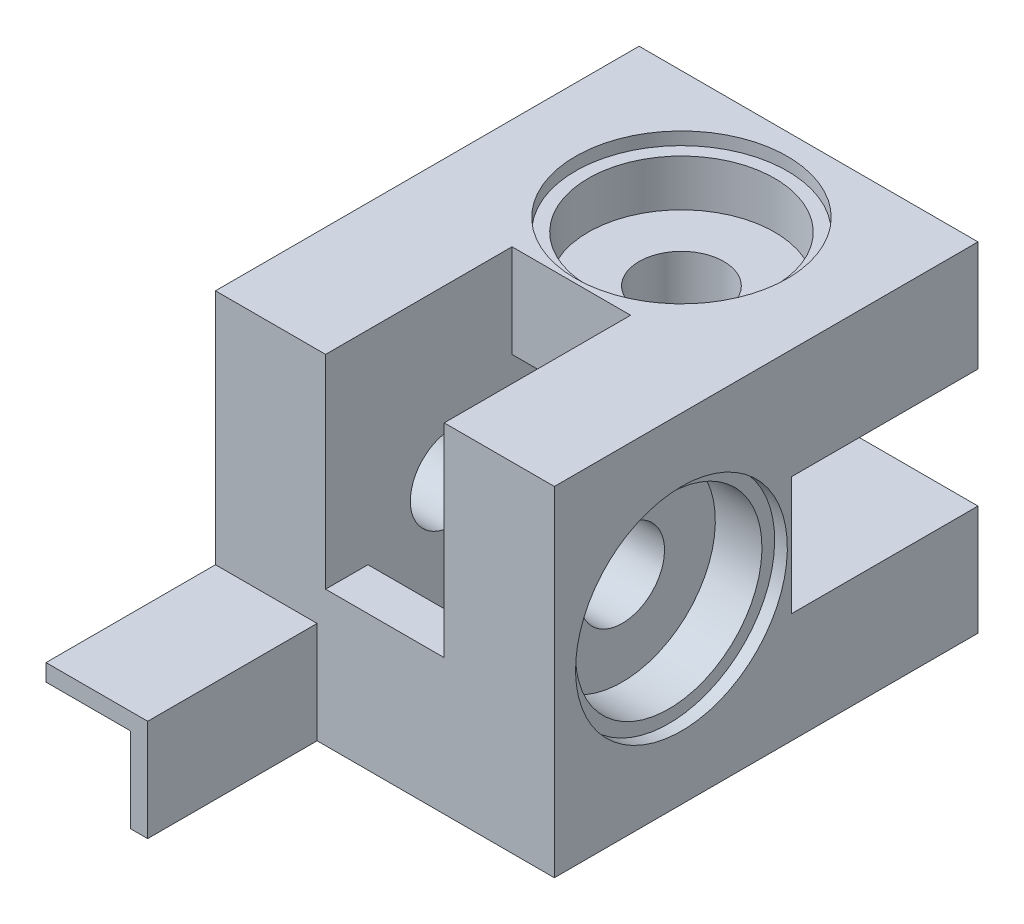
from build123d import *

# Parameters (mm, degrees)
ESQUISSE1_W              = 40
ESQUISSE1_H              = 40
BOSS_EXTRU_1_DEPTH       = 50
ESQUISSE2_R              = 5
ENL_V_MAT_EXTRU_1_DEPTH  = 41
ESQUISSE3_R              = 5
ENL_V_MAT_EXTRU_2_DEPTH  = 41
ESQUISSE4_W              = 20
ESQUISSE4_H              = 14
ENL_V_MAT_EXTRU_3_DEPTH  = 29
ESQUISSE5_W              = 14
ESQUISSE5_H              = 20
ENL_V_MAT_EXTRU_4_DEPTH  = 29
ESQUISSE6_W              = 22
ESQUISSE6_H              = 14
ENL_V_MAT_EXTRU_5_DEPTH  = 24
ESQUISSE7_W              = 14
ESQUISSE7_H              = 22
ENL_V_MAT_EXTRU_6_DEPTH  = 24
ESQUISSE8_R              = 11
ENL_V_MAT_EXTRU_7_DEPTH  = 7
ESQUISSE9_R              = 12.5
ENL_V_MAT_EXTRU_8_DEPTH  = 1.5
ESQUISSE10_R             = 11
ENL_V_MAT_EXTRU_9_DEPTH  = 7
ESQUISSE11_R             = 12.5
ENL_V_MAT_EXTRU_10_DEPTH = 1.5
BOSS_EXTRU_2_DEPTH       = 20


with BuildPart() as part:
    # Esquisse1 → Boss.-Extru.1 (new body)
    with BuildSketch(Plane.XY):
        with Locations((-20, 20)):
            Rectangle(ESQUISSE1_W, ESQUISSE1_H)
    extrude(amount=BOSS_EXTRU_1_DEPTH)

    # Esquisse2 → Enlèv. mat.-Extru.1 (cut, through all)
    with BuildSketch(Plane(origin=(0, 40, 0), x_dir=(1, 0, 0), z_dir=(0, 1, 0))):
        with Locations(Location((-20, -15, 0), (0, 0, 270))):  # turned: the seam where the file's is
            Circle(ESQUISSE2_R)
    extrude(amount=-ENL_V_MAT_EXTRU_1_DEPTH, mode=Mode.SUBTRACT)

    # Esquisse3 → Enlèv. mat.-Extru.2 (cut, through all)
    with BuildSketch(Plane.ZY.offset(40)):
        with Locations((35, 20)):
            Circle(ESQUISSE3_R)
    extrude(amount=-ENL_V_MAT_EXTRU_2_DEPTH, mode=Mode.SUBTRACT)

    # Esquisse4 → Enlèv. mat.-Extru.3 (cut)
    with BuildSketch(Plane.ZY.offset(40)):
        with Locations((15, 20)):
            Rectangle(ESQUISSE4_W, ESQUISSE4_H)
    extrude(amount=-ENL_V_MAT_EXTRU_3_DEPTH, mode=Mode.SUBTRACT)

    # Esquisse5 → Enlèv. mat.-Extru.4 (cut)
    with BuildSketch(Plane.XZ):
        with Locations((-20, 35)):
            Rectangle(ESQUISSE5_W, ESQUISSE5_H)
    extrude(amount=-ENL_V_MAT_EXTRU_4_DEPTH, mode=Mode.SUBTRACT)

    # Esquisse6 → Enlèv. mat.-Extru.5 (cut)
    with BuildSketch(Plane(origin=(0, 0, 0), x_dir=(0, 0, -1), z_dir=(1, 0, 0))):
        with Locations((-11, 20)):
            Rectangle(ESQUISSE6_W, ESQUISSE6_H)
    extrude(amount=-ENL_V_MAT_EXTRU_5_DEPTH, mode=Mode.SUBTRACT)

    # Esquisse7 → Enlèv. mat.-Extru.6 (cut)
    with BuildSketch(Plane(origin=(0, 40, 0), x_dir=(1, 0, 0), z_dir=(0, 1, 0))):
        with Locations((-20, -39)):
            Rectangle(ESQUISSE7_W, ESQUISSE7_H)
    extrude(amount=-ENL_V_MAT_EXTRU_6_DEPTH, mode=Mode.SUBTRACT)

    # Esquisse8 → Enlèv. mat.-Extru.7 (cut)
    with BuildSketch(Plane(origin=(0, 0, 0), x_dir=(0, 0, -1), z_dir=(1, 0, 0))):
        with Locations(Location((-35, 20, 0), (0, 0, 90))):  # turned: the seam where the file's is
            Circle(ESQUISSE8_R)
    extrude(amount=-ENL_V_MAT_EXTRU_7_DEPTH, mode=Mode.SUBTRACT)

    # Esquisse9 → Enlèv. mat.-Extru.8 (cut)
    with BuildSketch(Plane(origin=(0, 0, 0), x_dir=(0, 0, -1), z_dir=(1, 0, 0))):
        with Locations(Location((-35, 20, 0), (0, 0, 90))):  # turned: the seam where the file's is
            Circle(ESQUISSE9_R)
    extrude(amount=-ENL_V_MAT_EXTRU_8_DEPTH, mode=Mode.SUBTRACT)

    # Esquisse10 → Enlèv. mat.-Extru.9 (cut)
    with BuildSketch(Plane(origin=(0, 40, 0), x_dir=(1, 0, 0), z_dir=(0, 1, 0))):
        with Locations(Location((-20, -15, 0), (0, 0, 270))):  # turned: the seam where the file's is
            Circle(ESQUISSE10_R)
    extrude(amount=-ENL_V_MAT_EXTRU_9_DEPTH, mode=Mode.SUBTRACT)

    # Esquisse11 → Enlèv. mat.-Extru.10 (cut)
    with BuildSketch(Plane(origin=(0, 40, 0), x_dir=(1, 0, 0), z_dir=(0, 1, 0))):
        with Locations(Location((-20, -15, 0), (0, 0, 270))):  # turned: the seam where the file's is
            Circle(ESQUISSE11_R)
    extrude(amount=-ENL_V_MAT_EXTRU_10_DEPTH, mode=Mode.SUBTRACT)

    # Esquisse13 → Boss.-Extru.2 (add)
    with BuildSketch(Plane.XY.offset(50)):
        Polygon((-40, 10), (-30, 10), (-30, 0), (-28, 0), (-28, 12), (-40, 12), align=None)
    extrude(amount=BOSS_EXTRU_2_DEPTH)


solid = part.part
